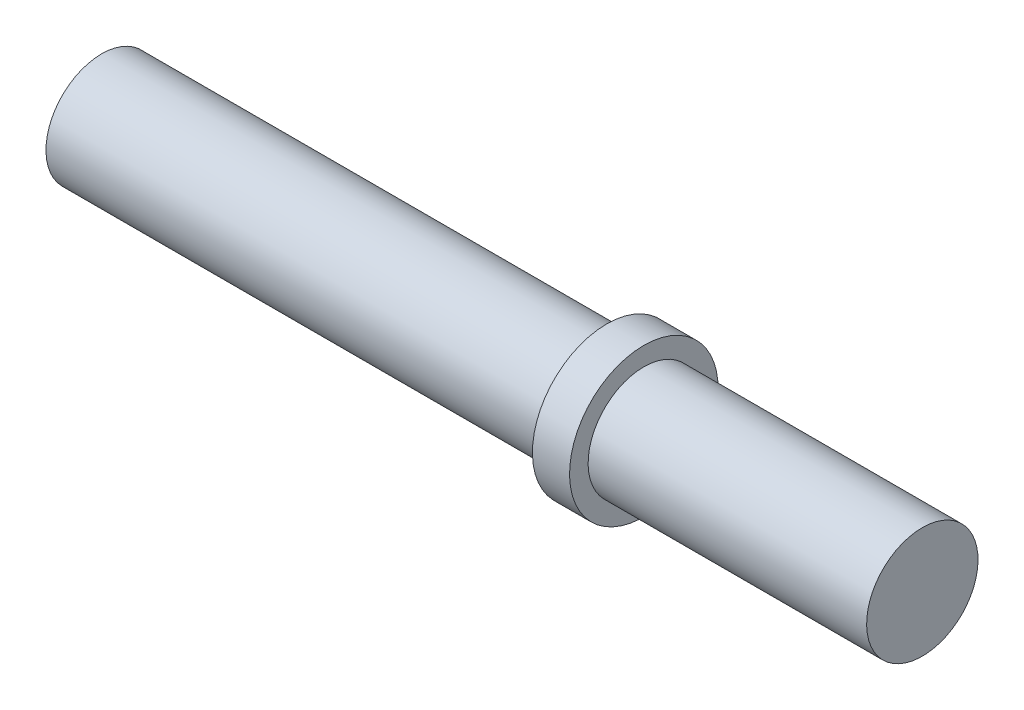
from build123d import *


with BuildPart() as part:
    # Sketch1 → Revolve1 (revolve)
    with BuildSketch(Plane.XY):
        Polygon((0, 3), (0, 0), (27.2, 0), (27.2, -1), (29.2, -1), (29.2, 0), (44.2, 0), (44.2, 3), align=None)
    revolve(axis=Axis((44.2, 3, 0), (-1, 0, 0)))


solid = part.part
